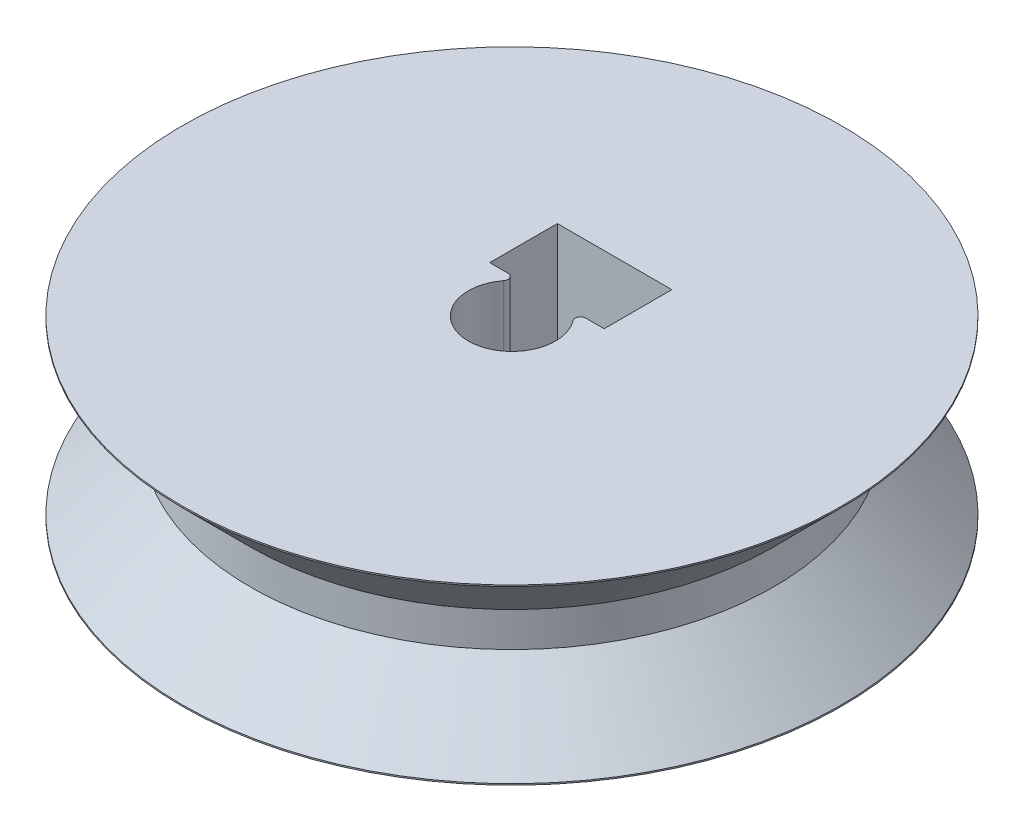
from build123d import *

# Parameters (mm, degrees)
CUT_EXTRUDE2_DEPTH      = 13.7
SKETCH9_W               = 8.382
SKETCH9_H               = 4.953
CUT_EXTRUDE3_DEPTH      = 13.7
FILLET2_R               = 0.396875
SKETCH14_W              = 1.7272
SKETCH14_H              = 21.5665
SKETCH15_R              = 3.429
CUT_EXTRUDE4_DEPTH      = 5.9800001
CUT_EXTRUDE4_DEPTH_BACK = 6.096
CUT_EXTRUDE6_START      = -19.15
SKETCH16_R              = 1.27
CUT_EXTRUDE6_DEPTH      = 25.1300001
CUT_EXTRUDE7_START      = -19.15
SKETCH16_3_R            = 2.54
CUT_EXTRUDE7_DEPTH      = 25.1300001


with BuildPart() as part:
    # Sketch7 → Revolve1 (revolve)
    with BuildSketch(Plane.XY):
        Polygon((0, 0), (24.13, 0), (24.13, 0.1), (19.15, 5.08), (19.15, 7.62), (24.13, 12.6), (24.13, 12.7), (0, 12.7), align=None)
    revolve(axis=Axis((0, 12.7, 0), (0, -1, 0)))

    # Sketch8 → Cut-Extrude2 (cut, through all)
    with BuildSketch(Plane(origin=(0, 12.7, 0), x_dir=(1, 0, 0), z_dir=(0, 1, 0))):
        with BuildLine():
            Line((-1.899409908, 2.5635), (1.899409908, 2.5635))
            ThreePointArc((1.899409908, 2.5635), (0, -3.1905), (-1.899409908, 2.5635))
        make_face()
    extrude(amount=-CUT_EXTRUDE2_DEPTH, mode=Mode.SUBTRACT)

    # Sketch9 → Cut-Extrude3 (cut, through all)
    with BuildSketch(Plane(origin=(0, 12.7, 0), x_dir=(1, 0, 0), z_dir=(0, 1, 0))):
        with Locations((0, 5.04)):
            Rectangle(SKETCH9_W, SKETCH9_H)
    extrude(amount=-CUT_EXTRUDE3_DEPTH, mode=Mode.SUBTRACT)

    # Fillet2
    fillet2_edges = [part.edges().sort_by_distance(p)[0] for p in [
        (1.899409908, 6.35, -2.5635),
        (-1.899409908, 6.35, -2.5635),
    ]]
    fillet(fillet2_edges, radius=FILLET2_R)

    # Sketch14 → 8-32 Tapped Hole1 (revolve, cut)
    with BuildSketch(Plane(origin=(0, 6.153258969, -2.5635), x_dir=(0, -1, 0), z_dir=(1, 0, 0))):
        with Locations((0.8636, 10.78325)):
            Rectangle(SKETCH14_W, SKETCH14_H)
    revolve(axis=Axis((0, 6.153258969, 3.7865), (0, 0, -1)), mode=Mode.SUBTRACT)

    # Sketch15 → Cut-Extrude4 (cut, two sides)
    with BuildSketch(Plane(origin=(0, 0, -19.15), x_dir=(-1, 0, 0), z_dir=(0, 0, -1))) as cut_extrude4_sk:
        with Locations((0, 6.35)):
            Circle(SKETCH15_R)
    extrude(amount=CUT_EXTRUDE4_DEPTH, mode=Mode.SUBTRACT)
    extrude(cut_extrude4_sk.sketch, amount=-CUT_EXTRUDE4_DEPTH_BACK, mode=Mode.SUBTRACT)

    # Sketch16 → Cut-Extrude6 (cut, through all)
    with BuildSketch(Plane(origin=(0, 0, -19.15), x_dir=(-1, 0, 0), z_dir=(0, 0, -1)).offset(CUT_EXTRUDE6_START)):
        with Locations((12.7, 6.35)):
            Circle(SKETCH16_R)
    extrude(amount=-CUT_EXTRUDE6_DEPTH, mode=Mode.SUBTRACT)

    # Sketch16_3 → Cut-Extrude7 (cut, through all)
    with BuildSketch(Plane(origin=(0, 0, -19.15), x_dir=(-1, 0, 0), z_dir=(0, 0, -1)).offset(CUT_EXTRUDE7_START)):
        with Locations((12.7, 6.35)):
            Circle(SKETCH16_3_R)
    extrude(amount=CUT_EXTRUDE7_DEPTH, mode=Mode.SUBTRACT)


solid = part.part
